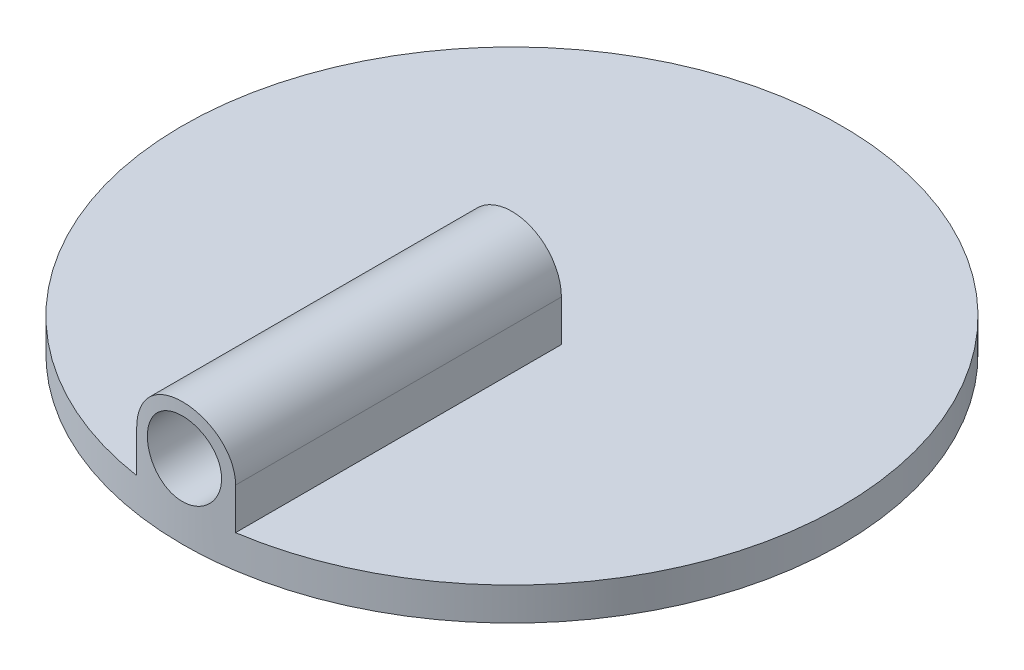
from build123d import *

# Parameters (mm, degrees)
SKETCH1_R                       = 20
BOSS_EXTRUDE1_DEPTH             = 2
BOSS_EXTRUDE2_REACH             = 30.355
BOSS_EXTRUDE2_END_RADIUS        = 20
SKETCH4_R                       = 2.25
BOSS_EXTRUDE2_DIRECTION_2_DEPTH = 0.0001


with BuildPart() as part:
    # Sketch1 → Boss-Extrude1 (new body)
    with BuildSketch(Plane(origin=(0, 0, 0), x_dir=(1, 0, 0), z_dir=(0, 1, 0))):
        Circle(SKETCH1_R)
    extrude(amount=BOSS_EXTRUDE1_DEPTH)

    # Boss-Extrude2: up to this cylinder (the profile starts inside it)
    boss_extrude2_end = Plane(origin=(0, 3.25, 0), z_dir=(0, -1, 0)) * Cylinder(BOSS_EXTRUDE2_END_RADIUS, 101.71, mode=Mode.PRIVATE)
    # Sketch4 → Boss-Extrude2 (add, up to the surface)
    with BuildSketch(Plane.XY, mode=Mode.PRIVATE) as boss_extrude2_sk1:
        with BuildLine():
            Line((-3, 4.5), (-3, 2))
            Line((-3, 2), (3, 2))
            Line((3, 2), (3, 4.5))
            ThreePointArc((3, 4.5), (0, 7.5), (-3, 4.5))
        make_face()
        with Locations((0, 4.5)):
            Circle(SKETCH4_R, mode=Mode.SUBTRACT)
    boss_extrude2_tool1 = extrude(boss_extrude2_sk1.sketch, amount=BOSS_EXTRUDE2_REACH, mode=Mode.PRIVATE) & boss_extrude2_end
    add(boss_extrude2_tool1.solids().sort_by_distance((-2.918606, 3.25, 0))[0])

    # Sketch4 → Boss-Extrude2 direction 2 (add)
    with BuildSketch(Plane.XY):
        with BuildLine():
            Line((-3, 4.5), (-3, 2))
            Line((-3, 2), (3, 2))
            Line((3, 2), (3, 4.5))
            ThreePointArc((3, 4.5), (0, 7.5), (-3, 4.5))
        make_face()
        with Locations((0, 4.5)):
            Circle(SKETCH4_R, mode=Mode.SUBTRACT)
    extrude(amount=-BOSS_EXTRUDE2_DIRECTION_2_DEPTH)


solid = part.part
